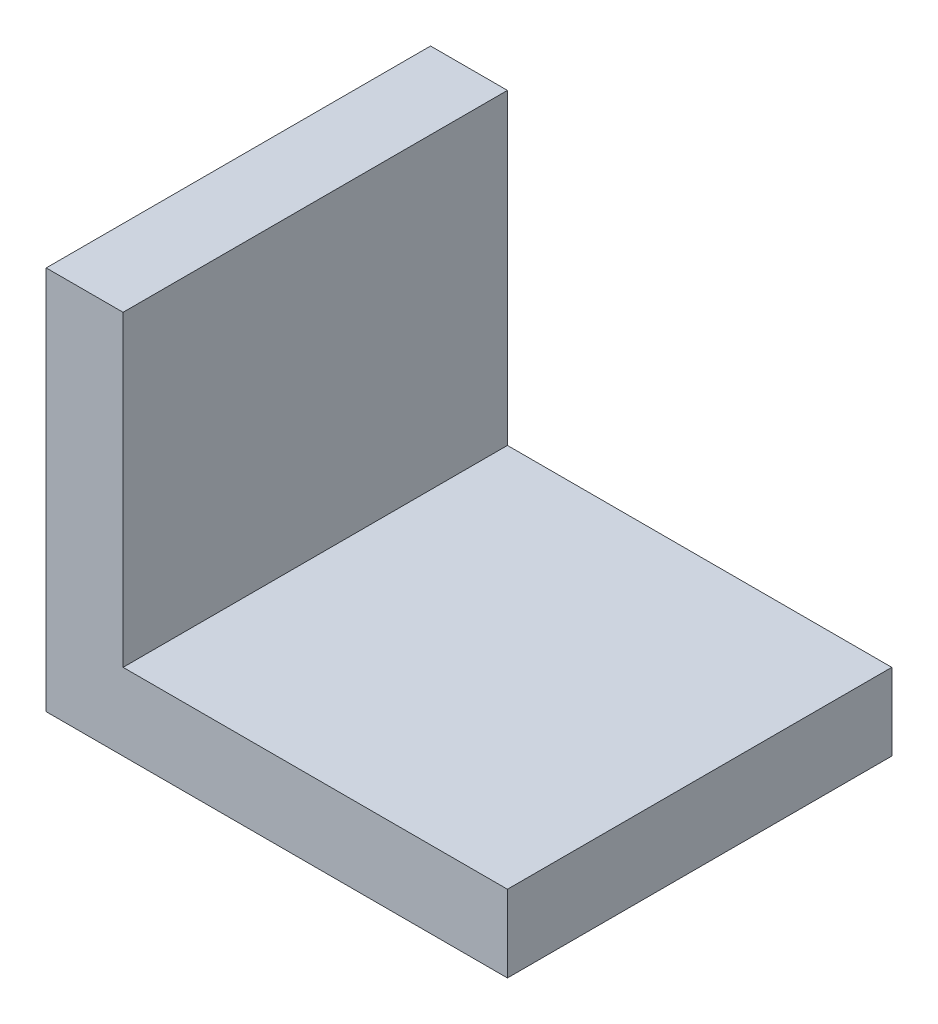
from build123d import *

# Parameters (mm, degrees)
SKETCH1_W           = 12
SKETCH1_H           = 10
BOSS_EXTRUDE1_DEPTH = 2
SKETCH2_W           = 2
SKETCH2_H           = 10
BOSS_EXTRUDE2_DEPTH = 8


with BuildPart() as part:
    # Sketch1 → Boss-Extrude1 (new body)
    with BuildSketch(Plane(origin=(0, 0, 0), x_dir=(1, 0, 0), z_dir=(0, 1, 0))):
        Rectangle(SKETCH1_W, SKETCH1_H)
    extrude(amount=BOSS_EXTRUDE1_DEPTH)

    # Sketch2 → Boss-Extrude2 (add)
    with BuildSketch(Plane(origin=(0, 2, 0), x_dir=(1, 0, 0), z_dir=(0, 1, 0))):
        with Locations((-5, 0)):
            Rectangle(SKETCH2_W, SKETCH2_H)
    extrude(amount=BOSS_EXTRUDE2_DEPTH)


solid = part.part
